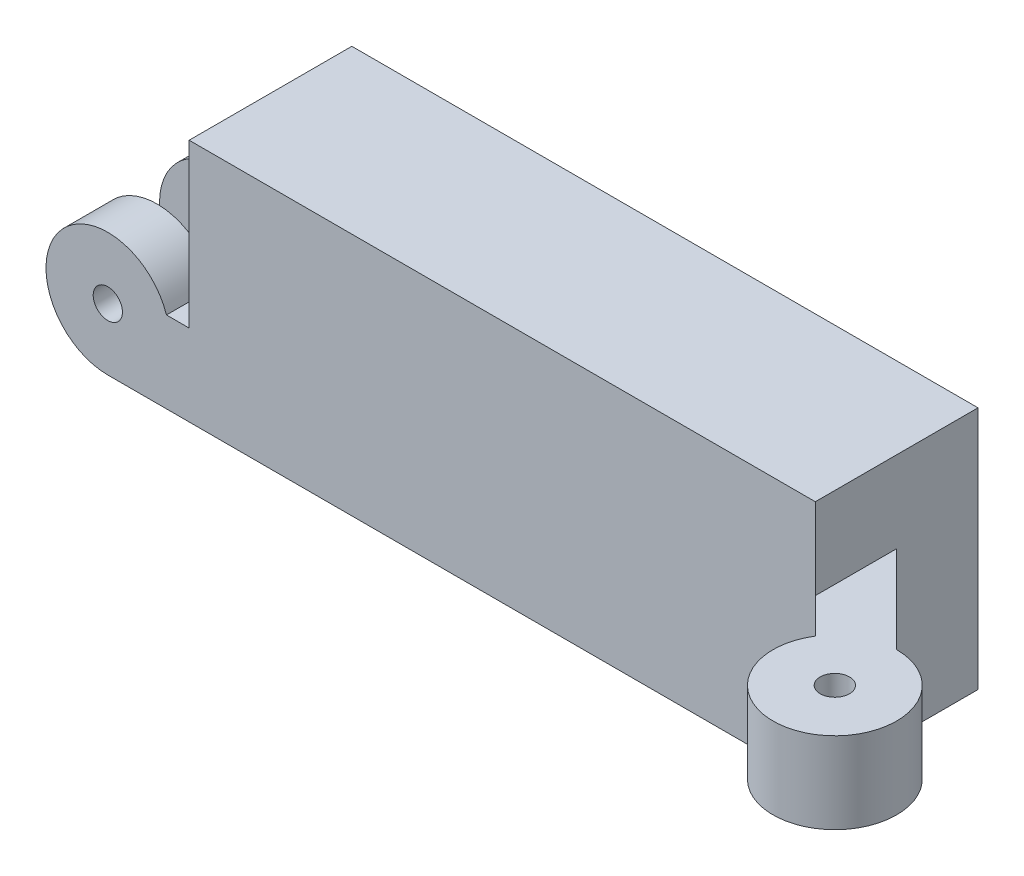
from build123d import *

# Parameters (mm, degrees)
SKETCH1_W           = 48.881284
SKETCH1_H           = 19.05
BOSS_EXTRUDE2_DEPTH = 12.7
BOSS_EXTRUDE3_DEPTH = 3.836458333
LPATTERN1_COUNT     = 2
LPATTERN1_PITCH     = 8.863541667
BOSS_EXTRUDE5_START = -9.525
SKETCH3_R           = 1.143
BOSS_EXTRUDE5_DEPTH = 3.175
SKETCH4_R           = 0.508
CUT_EXTRUDE1_DEPTH  = 7.62


with BuildPart() as part:
    # Sketch1 → Boss-Extrude2 (new body)
    with BuildSketch(Plane.XY):
        with Locations((24.440642, 9.525)):
            Rectangle(SKETCH1_W, SKETCH1_H)
    extrude(amount=BOSS_EXTRUDE2_DEPTH)

    # Sketch2 → Boss-Extrude3 (add)
    with BuildSketch(Plane(origin=(0, 0, 0), x_dir=(-1, 0, 0), z_dir=(0, 0, -1))):
        with BuildLine():
            ThreePointArc((1.77094988, 6.35), (2.435597108, 2.003283932), (6.35, 0))
            Line((6.35, 0), (6.35, 3.683))
            ThreePointArc((6.35, 3.683), (5.207, 4.826), (6.35, 5.969))
            Line((6.35, 5.969), (6.35, 6.35))
            Line((6.35, 6.35), (1.77094988, 6.35))
        make_face()
        with BuildLine():
            Line((6.35, 3.683), (6.35, 0))
            ThreePointArc((6.35, 0), (9.762497326, 1.413502674), (11.176, 4.826))
            ThreePointArc((11.176, 4.826), (7.121939156, 9.589862502), (1.77094988, 6.35))
            Line((1.77094988, 6.35), (6.35, 6.35))
            Line((6.35, 6.35), (6.35, 5.969))
            ThreePointArc((6.35, 5.969), (7.158223051, 5.634223051), (7.493, 4.826))
            ThreePointArc((7.493, 4.826), (7.158223051, 4.017776949), (6.35, 3.683))
        make_face()
        with BuildLine():
            Line((0, 6.35), (0, 0))
            Line((0, 0), (6.35, 0))
            ThreePointArc((6.35, 0), (2.435597108, 2.003283932), (1.77094988, 6.35))
            Line((1.77094988, 6.35), (0, 6.35))
        make_face()
    boss_extrude3 = extrude(amount=-BOSS_EXTRUDE3_DEPTH)

    # LPattern1: Boss-Extrude3 ×2
    with Locations(*[(0, 0, i * LPATTERN1_PITCH) for i in range(1, LPATTERN1_COUNT)]):
        add(boss_extrude3)

    # Sketch3 → Boss-Extrude5 (add, symmetric)
    with BuildSketch(Plane.XZ.offset(BOSS_EXTRUDE5_START)):
        with BuildLine():
            Line((51.617945235, 15.436661235), (48.881284, 12.7))
            Line((48.881284, 12.7), (48.881284, 6.35))
            Line((48.881284, 6.35), (55.706278652, 13.174994652))
            ThreePointArc((55.706278652, 13.174994652), (58.04238684, 22.223893483), (51.617945235, 15.436661235))
        make_face()
        with Locations(Location((55.706278652, 18.000994652, 0), (0, 0, 270))):
            Circle(SKETCH3_R, mode=Mode.SUBTRACT)
    extrude(amount=BOSS_EXTRUDE5_DEPTH, both=True)

    # Sketch4 → Cut-Extrude1 (cut)
    with BuildSketch(Plane(origin=(0, 0, 0), x_dir=(-1, 0, 0), z_dir=(0, 0, -1))):
        with Locations((-45.579284, 9.525)):
            Circle(SKETCH4_R)
        with Locations((-3.067304, 9.525)):
            Circle(SKETCH4_R)
    extrude(amount=-CUT_EXTRUDE1_DEPTH, mode=Mode.SUBTRACT)


solid = part.part
